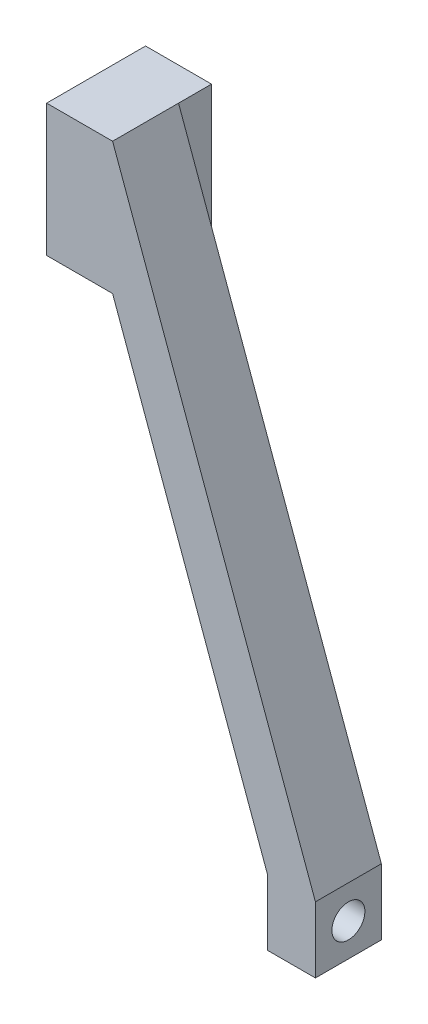
from build123d import *

# Parameters (mm, degrees)
BOSS_EXTRUDE1_DEPTH = 12.7
SKETCH2_R           = 3.175
CUT_EXTRUDE1_DEPTH  = 10.24484395
SKETCH5_W           = 12.7
SKETCH5_H           = 25.4
BOSS_EXTRUDE2_DEPTH = 6.35
SKETCH4_R           = 3.175
CUT_EXTRUDE2_DEPTH  = 19.05


with BuildPart() as part:
    # Sketch1 → Boss-Extrude1 (new body)
    with BuildSketch(Plane.XY):
        Polygon((0, 0), (0, 25.4), (12.7, 25.4), (51.754006137, -81.9), (51.754006137, -94.6), (42.509162186, -94.6), (42.509162186, -81.9), (12.7, 0), align=None)
    extrude(amount=-BOSS_EXTRUDE1_DEPTH)

    # Sketch2 → Cut-Extrude1 (cut, through all)
    with BuildSketch(Plane.ZY.offset(-42.509162186)):
        with Locations((-6.35, -88.25)):
            Circle(SKETCH2_R)
    extrude(amount=-CUT_EXTRUDE1_DEPTH, mode=Mode.SUBTRACT)

    # Sketch5 → Boss-Extrude2 (add)
    with BuildSketch(Plane.XY.offset(-12.7)):
        with Locations((6.35, 12.7)):
            Rectangle(SKETCH5_W, SKETCH5_H)
    extrude(amount=-BOSS_EXTRUDE2_DEPTH)

    # Sketch4 → Cut-Extrude2 (cut)
    with BuildSketch(Plane.XZ):
        with Locations((6.35, -12.7)):
            Circle(SKETCH4_R)
    extrude(amount=-CUT_EXTRUDE2_DEPTH, mode=Mode.SUBTRACT)


solid = part.part
